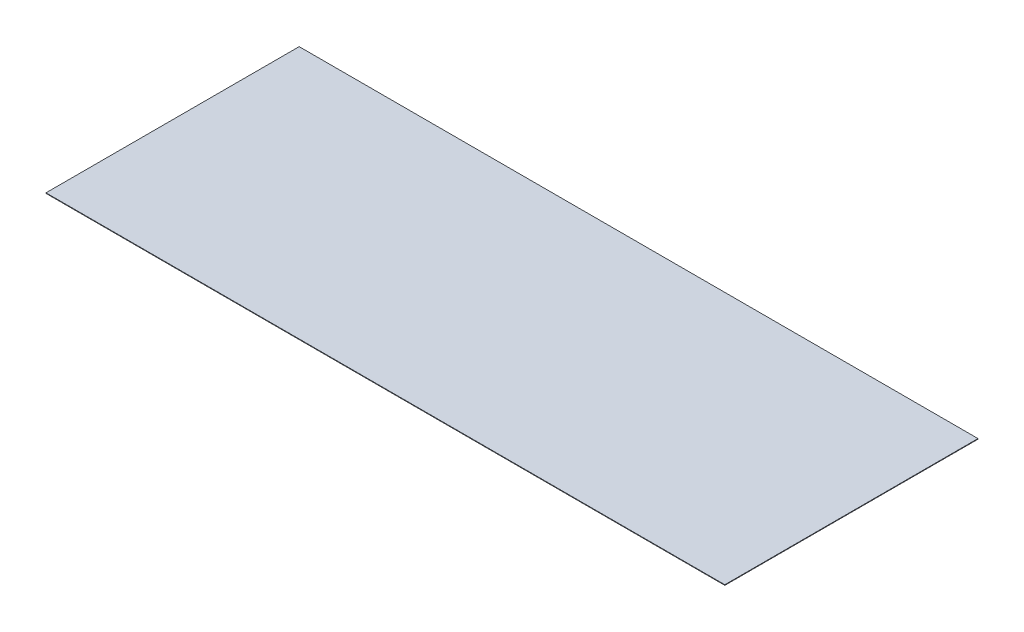
from build123d import *

# Parameters (mm, degrees)
CROQUIS1_W              = 2440
CROQUIS1_H              = 910
SALIENTE_EXTRUIR1_DEPTH = 2


with BuildPart() as part:
    # Croquis1 → Saliente-Extruir1 (new body)
    with BuildSketch(Plane(origin=(0, 0, 0), x_dir=(1, 0, 0), z_dir=(0, 1, 0))):
        Rectangle(CROQUIS1_W, CROQUIS1_H)
    extrude(amount=SALIENTE_EXTRUIR1_DEPTH)


solid = part.part
